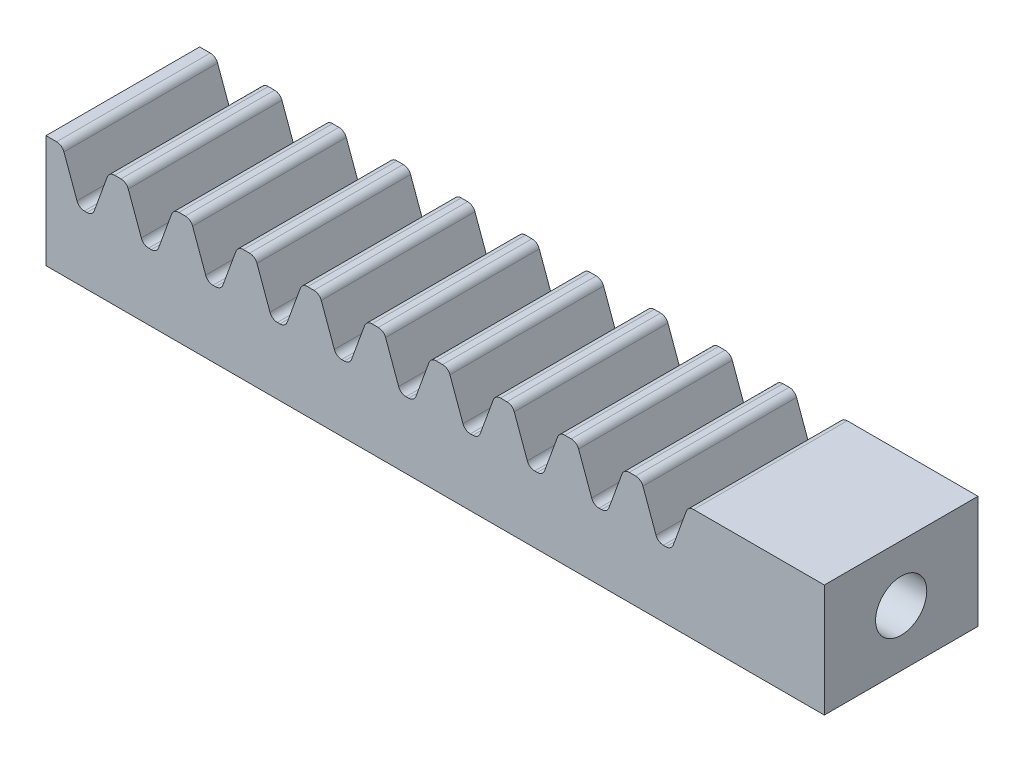
from build123d import *

# Parameters (mm, degrees)
SKETCH_1_W                     = 108
SKETCH_1_H                     = 11
EXTRUDE_1_DEPTH                = 7.5
CUT_EXTRUDE_1_DEPTH            = 16
FILLET_1_R                     = 0.76
PATTERN_LINEAR_1_COUNT         = 17
PATTERN_LINEAR_1_PITCH         = 6.28
FILLET_1_OF_PATTERN_LINEAR_1_R = 0.76
SKETCH_3_W                     = 15
SKETCH_3_H                     = 11
EXTRUDE_2_DEPTH                = 44.58
SKETCH_4_W                     = 15
SKETCH_4_H                     = 11
CUT_EXTRUDE_2_DEPTH            = 33.02
SKETCH_5_R                     = 2.5
CUT_EXTRUDE_3_DEPTH            = 10


with BuildPart() as part:
    # 草图1 → 凸台-拉伸1 (new body, symmetric)
    with BuildSketch(Plane.XY):
        Rectangle(SKETCH_1_W, SKETCH_1_H)
    extrude(amount=EXTRUDE_1_DEPTH, both=True)

    # 草图2 → 切除-拉伸1 (cut, through all)
    with BuildSketch(Plane.XY.offset(7.5)):
        Polygon((-52.43, 5.5), (-47.834119063, 5.5), (-49.471985117, 1), (-50.792133946, 1), align=None)
    cut_extrude_1 = extrude(amount=-CUT_EXTRUDE_1_DEPTH, mode=Mode.SUBTRACT)

    # 圆角1
    fillet_1_edges = [part.edges().sort_by_distance(p)[0] for p in [
        (-50.792133946, 1, 0),
        (-52.43, 5.5, 0),
        (-47.834119063, 5.5, 0),
        (-49.471985117, 1, 0),
    ]]
    fillet(fillet_1_edges, radius=FILLET_1_R)

    # 阵列(线性)1: 切除-拉伸1 ×17
    with Locations(*[(i * PATTERN_LINEAR_1_PITCH, 0, 0) for i in range(1, PATTERN_LINEAR_1_COUNT)]):
        add(cut_extrude_1, mode=Mode.SUBTRACT)

    # 圆角1 of 阵列(线性)1
    fillet_1_of_pattern_linear_1_edges = [part.edges().sort_by_distance(p)[0] for p in [
        (-44.512133946, 1, 0),
        (-46.15, 5.5, 0),
        (-41.554119063, 5.5, 0),
        (-43.191985117, 1, 0),
        (-38.232133946, 1, 0),
        (-39.87, 5.5, 0),
        (-35.274119063, 5.5, 0),
        (-36.911985117, 1, 0),
        (-31.952133946, 1, 0),
        (-33.59, 5.5, 0),
        (-28.994119063, 5.5, 0),
        (-30.631985117, 1, 0),
        (-25.672133946, 1, 0),
        (-27.31, 5.5, 0),
        (-22.714119063, 5.5, 0),
        (-24.351985117, 1, 0),
        (-19.392133946, 1, 0),
        (-21.03, 5.5, 0),
        (-16.434119063, 5.5, 0),
        (-18.071985117, 1, 0),
        (-13.112133946, 1, 0),
        (-14.75, 5.5, 0),
        (-10.154119063, 5.5, 0),
        (-11.791985117, 1, 0),
        (-6.832133946, 1, 0),
        (-8.47, 5.5, 0),
        (-3.874119063, 5.5, 0),
        (-5.511985117, 1, 0),
        (-0.552133946, 1, 0),
        (-2.19, 5.5, 0),
        (2.405880937, 5.5, 0),
        (0.768014883, 1, 0),
        (5.727866054, 1, 0),
        (4.09, 5.5, 0),
        (8.685880937, 5.5, 0),
        (7.048014883, 1, 0),
        (12.007866054, 1, 0),
        (10.37, 5.5, 0),
        (14.965880937, 5.5, 0),
        (13.328014883, 1, 0),
        (18.287866054, 1, 0),
        (16.65, 5.5, 0),
        (21.245880937, 5.5, 0),
        (19.608014883, 1, 0),
        (24.567866054, 1, 0),
        (22.93, 5.5, 0),
        (27.525880937, 5.5, 0),
        (25.888014883, 1, 0),
        (30.847866054, 1, 0),
        (29.21, 5.5, 0),
        (33.805880937, 5.5, 0),
        (32.168014883, 1, 0),
        (37.127866054, 1, 0),
        (35.49, 5.5, 0),
        (40.085880937, 5.5, 0),
        (38.448014883, 1, 0),
        (43.407866054, 1, 0),
        (41.77, 5.5, 0),
        (46.365880937, 5.5, 0),
        (44.728014883, 1, 0),
        (49.687866054, 1, 0),
        (48.05, 5.5, 0),
        (52.645880937, 5.5, 0),
        (51.008014883, 1, 0),
    ]]
    fillet(fillet_1_of_pattern_linear_1_edges, radius=FILLET_1_OF_PATTERN_LINEAR_1_R)

    # 草图3 → 凸台-拉伸2 (add)
    with BuildSketch(Plane(origin=(9.42, 0, 0), x_dir=(0, 0, -1), z_dir=(1, 0, 0))):
        Rectangle(SKETCH_3_W, SKETCH_3_H)
    extrude(amount=EXTRUDE_2_DEPTH)

    # 草图4 → 切除-拉伸2 (cut, through all)
    with BuildSketch(Plane(origin=(21.98, 0, 0), x_dir=(0, 0, -1), z_dir=(1, 0, 0))):
        Rectangle(SKETCH_4_W, SKETCH_4_H)
    extrude(amount=CUT_EXTRUDE_2_DEPTH, mode=Mode.SUBTRACT)

    # 草图5 → 切除-拉伸3 (cut)
    with BuildSketch(Plane(origin=(21.98, 0, 0), x_dir=(0, 0, -1), z_dir=(1, 0, 0))):
        Circle(SKETCH_5_R)
    extrude(amount=-CUT_EXTRUDE_3_DEPTH, mode=Mode.SUBTRACT)


solid = part.part
